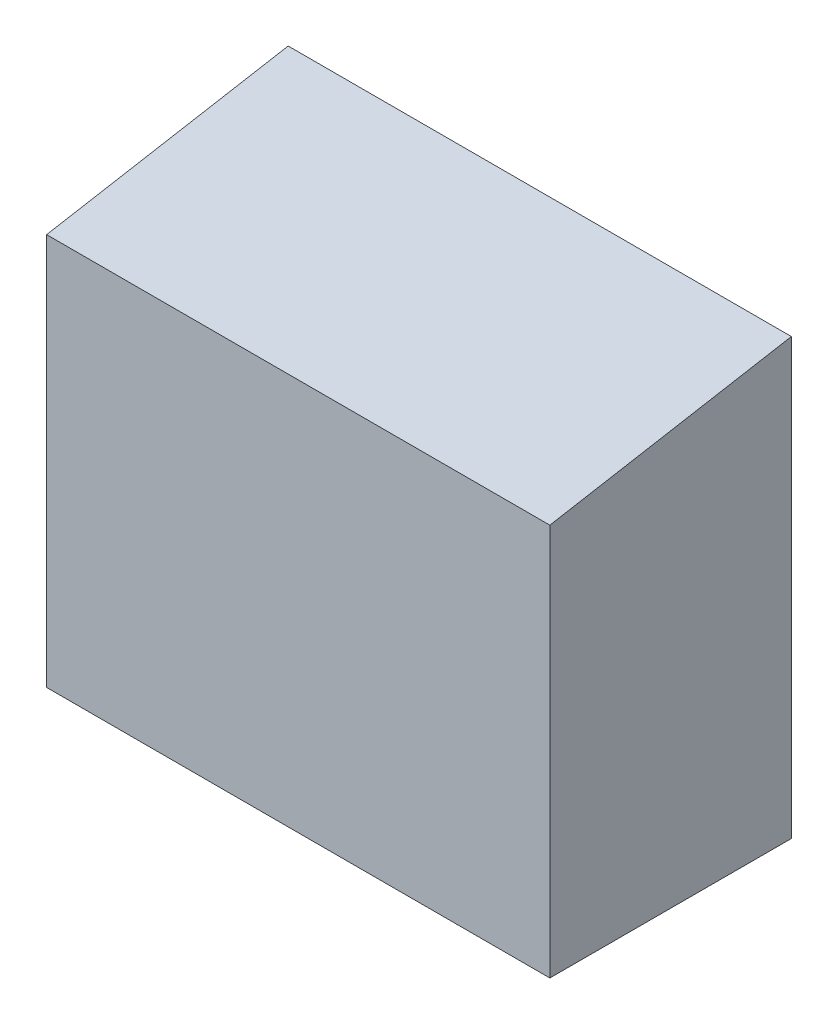
from build123d import *

# Parameters (mm, degrees)
BOSS_EXTRUDE2_DEPTH         = 39.6875
F_1_4_20_TAPPED_HOLE1_D     = 5.1054
F_1_4_20_TAPPED_HOLE1_DEPTH = 22.86
F_1_4_20_TAPPED_HOLE1_TIP   = 1.533816902


with BuildPart() as part:
    # Sketch3 → Boss-Extrude2 (new body, symmetric)
    with BuildSketch(Plane(origin=(0, 0, 0), x_dir=(0, 0, -1), z_dir=(1, 0, 0))):
        Polygon((0, 0), (38.1, 0), (38.1, 68.58), (0, 61.861942035), align=None)
    extrude(amount=BOSS_EXTRUDE2_DEPTH, both=True)

    # 1/4-20 Tapped Hole1
    with Locations(Plane(origin=(0, 0, 0), x_dir=(-1, 0, 0), z_dir=(0, -1, 0))):
        with Locations((25.4, 19.05), (-25.4, 19.05)):
            Hole(F_1_4_20_TAPPED_HOLE1_D / 2, depth=F_1_4_20_TAPPED_HOLE1_DEPTH)
            with Locations((0, 0, -(F_1_4_20_TAPPED_HOLE1_DEPTH + F_1_4_20_TAPPED_HOLE1_TIP / 2))):  # 118° drill point
                Cone(0, F_1_4_20_TAPPED_HOLE1_D / 2, F_1_4_20_TAPPED_HOLE1_TIP, mode=Mode.SUBTRACT)


solid = part.part
